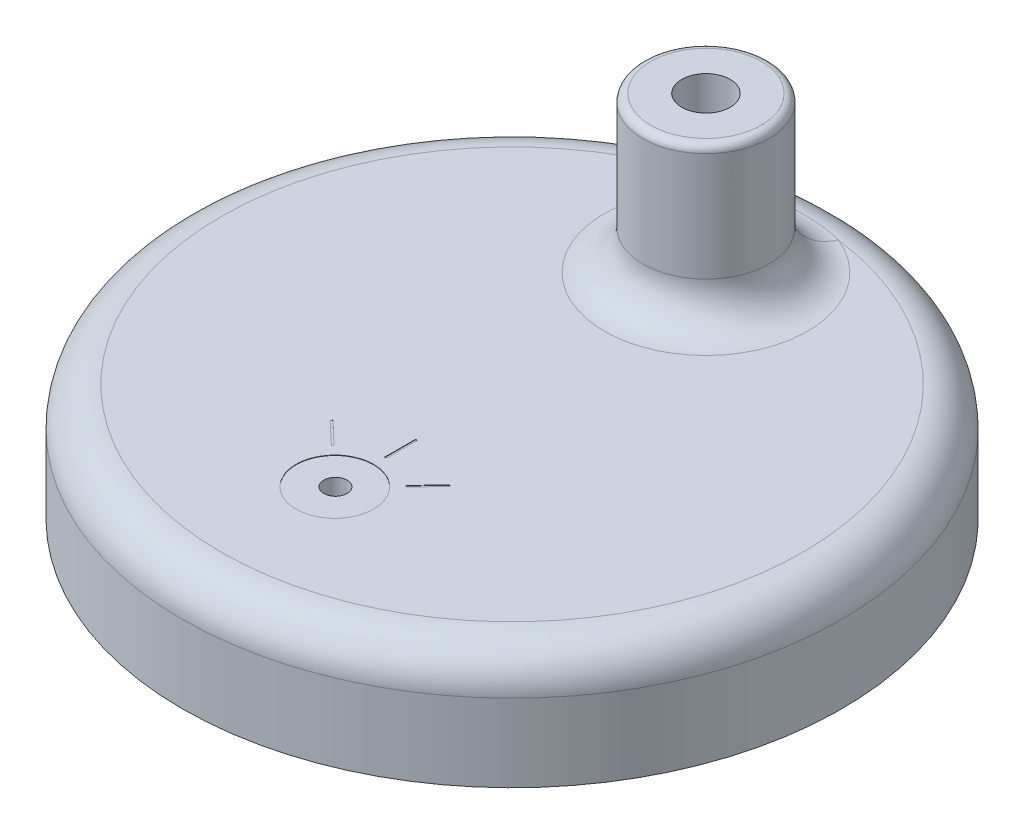
from build123d import *

# Parameters (mm, degrees)
SKETCH1_R           = 85
BOSS_EXTRUDE1_DEPTH = 30
FILLET1_R           = 10
SHELL1_T            = -8
SKETCH1_2_R         = 85
BOSS_EXTRUDE3_DEPTH = 5
SKETCH2_R           = 16.25
SKETCH2_R_2         = 6.25
BOSS_EXTRUDE2_DEPTH = 40
CUT_EXTRUDE1_REACH  = 128.689
SKETCH2_3_R         = 6.25
FILLET2_R           = 10
FILLET3_R           = 2
SKETCH3_R           = 3
CUT_EXTRUDE2_DEPTH  = 5
SKETCH4_R           = 10
SKETCH4_W           = 0.5
SKETCH4_H           = 8
CUT_EXTRUDE3_DEPTH  = 0.1


with BuildPart() as part:
    # Sketch1 → Boss-Extrude1 (new body)
    with BuildSketch(Plane(origin=(0, 0, 0), x_dir=(1, 0, 0), z_dir=(0, 1, 0))):
        Circle(SKETCH1_R)
    extrude(amount=BOSS_EXTRUDE1_DEPTH)

    # Fillet1
    fillet1_edges = [part.edges().sort_by_distance(p)[0] for p in [
        (-85, 30, 0),
    ]]
    fillet(fillet1_edges, radius=FILLET1_R)

    # Shell1
    shell1_openings = [part.faces().sort_by_distance(p)[0] for p in [
        (0, 0, 0),
    ]]
    offset(amount=SHELL1_T, openings=shell1_openings, kind=Kind.INTERSECTION)

    # Sketch1_2 → Boss-Extrude3 (add)
    with BuildSketch(Plane(origin=(0, 0, 0), x_dir=(1, 0, 0), z_dir=(0, 1, 0))):
        Circle(SKETCH1_2_R)
    extrude(amount=BOSS_EXTRUDE3_DEPTH)

    # Sketch2 → Boss-Extrude2 (add)
    with BuildSketch(Plane(origin=(0, 30, 0), x_dir=(1, 0, 0), z_dir=(0, 1, 0))):
        with Locations((0, 50)):
            Circle(SKETCH2_R)
        with Locations((0, 50)):
            Circle(SKETCH2_R_2, mode=Mode.SUBTRACT)
    extrude(amount=BOSS_EXTRUDE2_DEPTH)

    # Sketch2_3 → Cut-Extrude1 (cut, up to next)
    with BuildSketch(Plane(origin=(0, 30, 0), x_dir=(1, 0, 0), z_dir=(0, 1, 0)), mode=Mode.PRIVATE) as cut_extrude1_sk1:
        with Locations((0, 50)):
            Circle(SKETCH2_3_R)
    cut_extrude1_tool1 = extrude(cut_extrude1_sk1.sketch, amount=-CUT_EXTRUDE1_REACH, mode=Mode.PRIVATE) & part.part
    add(cut_extrude1_tool1.solids().sort_by_distance((0, 30, -50))[0], mode=Mode.SUBTRACT)

    # Fillet2
    fillet2_edges = [part.edges().sort_by_distance(p)[0] for p in [
        (-16.25, 30, -50),
    ]]
    fillet(fillet2_edges, radius=FILLET2_R)

    # Fillet3
    fillet3_edges = [part.edges().sort_by_distance(p)[0] for p in [
        (-16.25, 70, -50),
    ]]
    fillet(fillet3_edges, radius=FILLET3_R)

    # Sketch3 → Cut-Extrude2 (cut)
    with BuildSketch(Plane(origin=(0, 30, 0), x_dir=(1, 0, 0), z_dir=(0, 1, 0))):
        with Locations((0, -45.554448546)):
            Circle(SKETCH3_R)
    extrude(amount=-CUT_EXTRUDE2_DEPTH, mode=Mode.SUBTRACT)

    # Sketch4 → Cut-Extrude3 (cut)
    with BuildSketch(Plane(origin=(0, 30, 0), x_dir=(1, 0, 0), z_dir=(0, 1, 0))):
        with Locations((0, -45.718475917)):
            Circle(SKETCH4_R)
        Polygon((8.929220054, -36.270245709), (9.292745114, -36.613537902), (14.78542021, -30.797136927), (14.421895149, -30.453844734), align=None)
        with Locations((0.080103939, -28.718475917)):
            Rectangle(SKETCH4_W, SKETCH4_H)
        Polygon((-9.280005487, -36.611116357), (-9.623297681, -36.974641418), (-15.439698655, -31.481966322), (-15.096406462, -31.118441261), align=None)
    extrude(amount=-CUT_EXTRUDE3_DEPTH, mode=Mode.SUBTRACT)


solid = part.part
